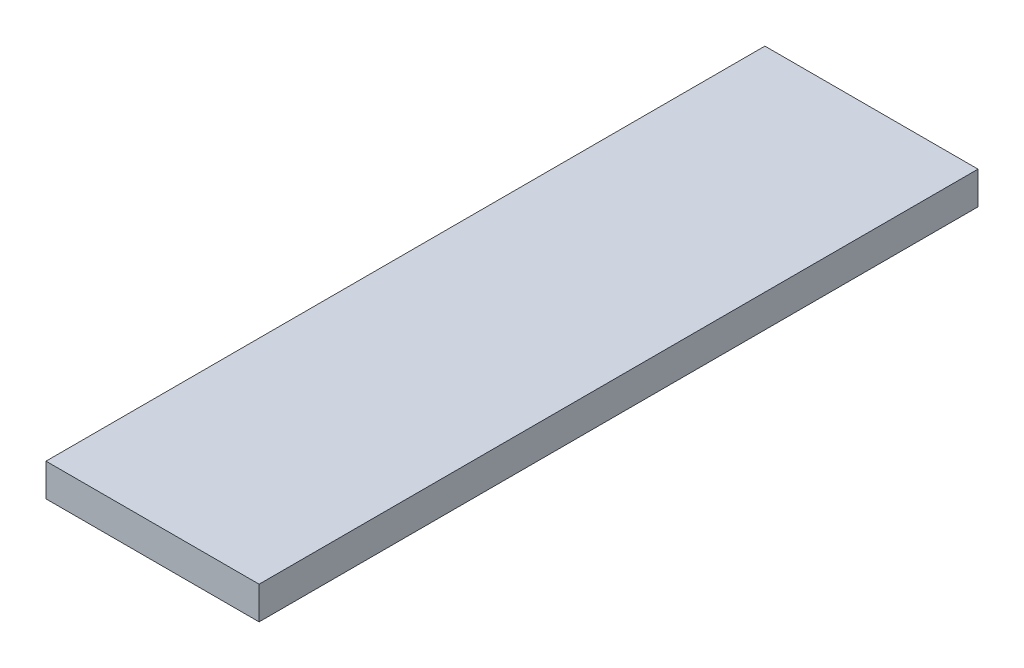
from build123d import *

# Parameters (mm, degrees)
SKETCH1_W           = 41.411629014
SKETCH1_H           = 139.7
BOSS_EXTRUDE1_DEPTH = 6.35


with BuildPart() as part:
    # Sketch1 → Boss-Extrude1 (new body)
    with BuildSketch(Plane(origin=(0, 0, 0), x_dir=(1, 0, 0), z_dir=(0, 1, 0))):
        Rectangle(SKETCH1_W, SKETCH1_H)
    extrude(amount=-BOSS_EXTRUDE1_DEPTH)


solid = part.part
